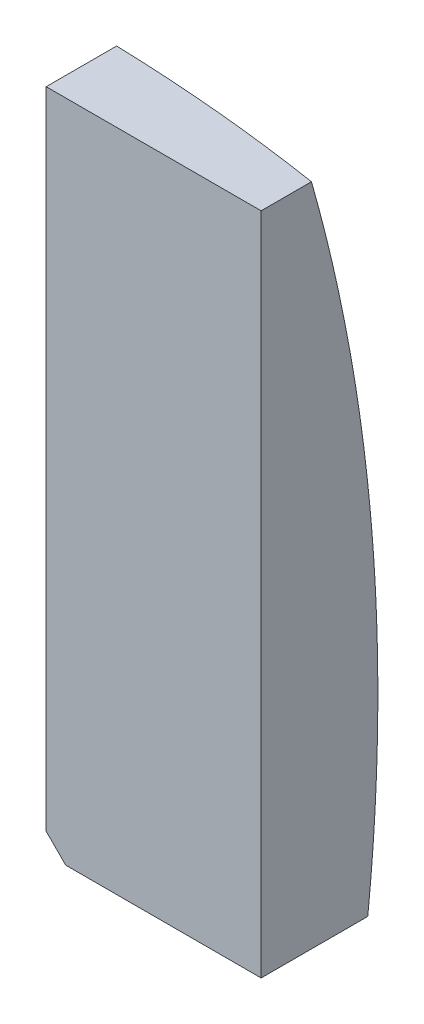
from build123d import *

# Parameters (mm, degrees)
SKETCH_2_OUTSIDE_W   = 37.95
SKETCH_2_OUTSIDE_H   = 37.95
SKETCH_2_OUTSIDE_W_2 = 5.5
SKETCH_2_OUTSIDE_H_2 = 17
CUT_EXTRUDE_1_DEPTH  = 4.5
CHAMFER_3_SIZE       = 0.5


with BuildPart() as part:
    # Эскиз1 → Повернуть1 (revolve)
    with BuildSketch(Plane(origin=(0, 0, 0), x_dir=(1, 0, 0), z_dir=(0, 1, 0))):
        with BuildLine():
            Line((14, 0), (14, 1.276685932))
            ThreePointArc((14, 1.276685932), (7.087720463, 2.940710488), (0, 3.5))
            Line((0, 3.5), (0, 0))
            Line((0, 0), (14, 0))
        make_face()
    revolve(axis=Axis((0, 0, -3.5), (0, 0, 1)))

    # Эскиз2 outside → Вырез-Вытянуть1 (cut, through all)
    with BuildSketch(Plane.XY):
        Rectangle(SKETCH_2_OUTSIDE_W, SKETCH_2_OUTSIDE_H)
        with Locations((4.05, 3.7)):
            Rectangle(SKETCH_2_OUTSIDE_W_2, SKETCH_2_OUTSIDE_H_2, mode=Mode.SUBTRACT)
    extrude(amount=-CUT_EXTRUDE_1_DEPTH, mode=Mode.SUBTRACT)

    # Фаска3
    chamfer_3_edges = [part.edges().sort_by_distance(p)[0] for p in [
        (1.3, -4.8, -1.61277204),
    ]]
    chamfer(chamfer_3_edges, length=CHAMFER_3_SIZE)


solid = part.part
